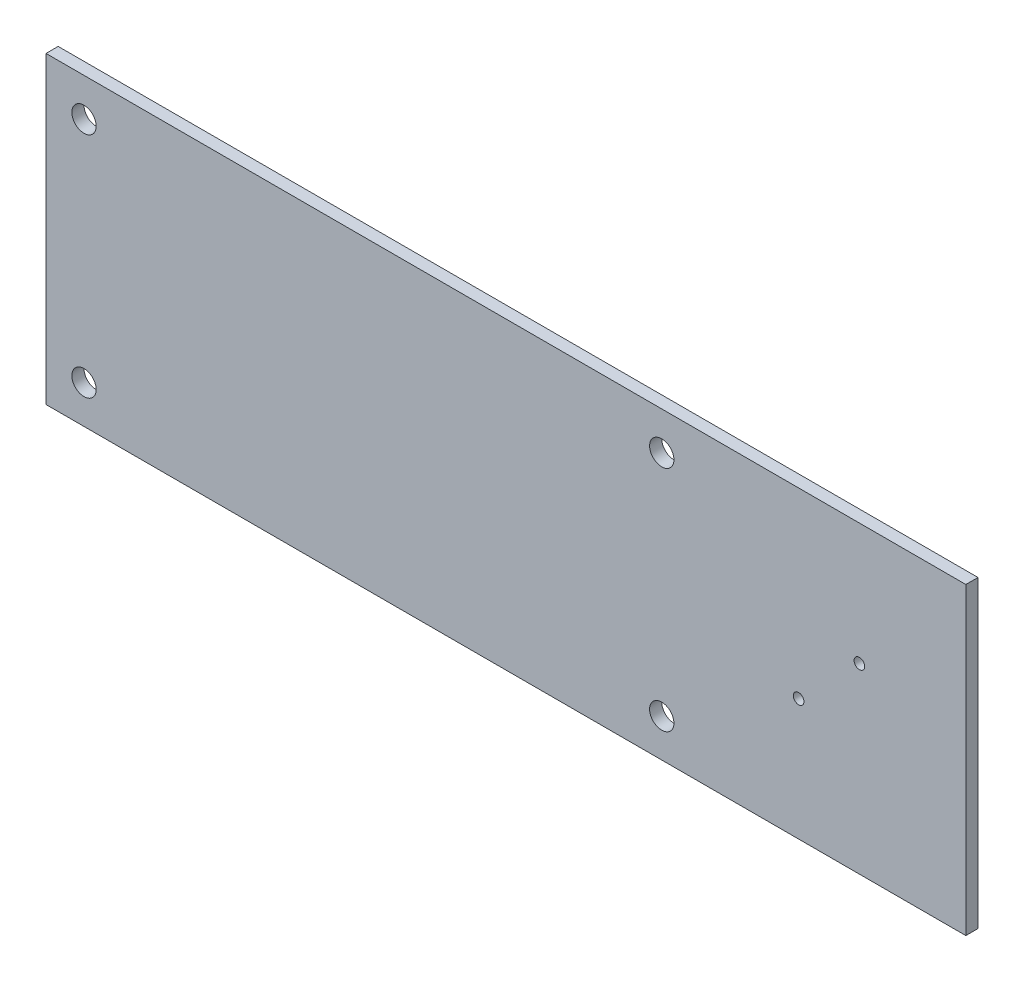
from build123d import *

# Parameters (mm, degrees)
ESQUISSE1_W        = 121
ESQUISSE1_H        = 40
ESQUISSE1_R        = 1.6
ESQUISSE1_R_2      = 0.7
BOSS_EXTRU_1_DEPTH = 1.6


with BuildPart() as part:
    # Esquisse1 → Boss.-Extru.1 (new body)
    with BuildSketch(Plane.XY):
        with Locations((60.5, 20)):
            Rectangle(ESQUISSE1_W, ESQUISSE1_H)
        with Locations((5, 35)):
            Circle(ESQUISSE1_R, mode=Mode.SUBTRACT)
        with Locations((5, 5)):
            Circle(ESQUISSE1_R, mode=Mode.SUBTRACT)
        with Locations((81, 5)):
            Circle(ESQUISSE1_R, mode=Mode.SUBTRACT)
        with Locations((81, 35)):
            Circle(ESQUISSE1_R, mode=Mode.SUBTRACT)
        with Locations((107, 24)):
            Circle(ESQUISSE1_R_2, mode=Mode.SUBTRACT)
        with Locations((99, 16)):
            Circle(ESQUISSE1_R_2, mode=Mode.SUBTRACT)
    extrude(amount=BOSS_EXTRU_1_DEPTH)


solid = part.part
